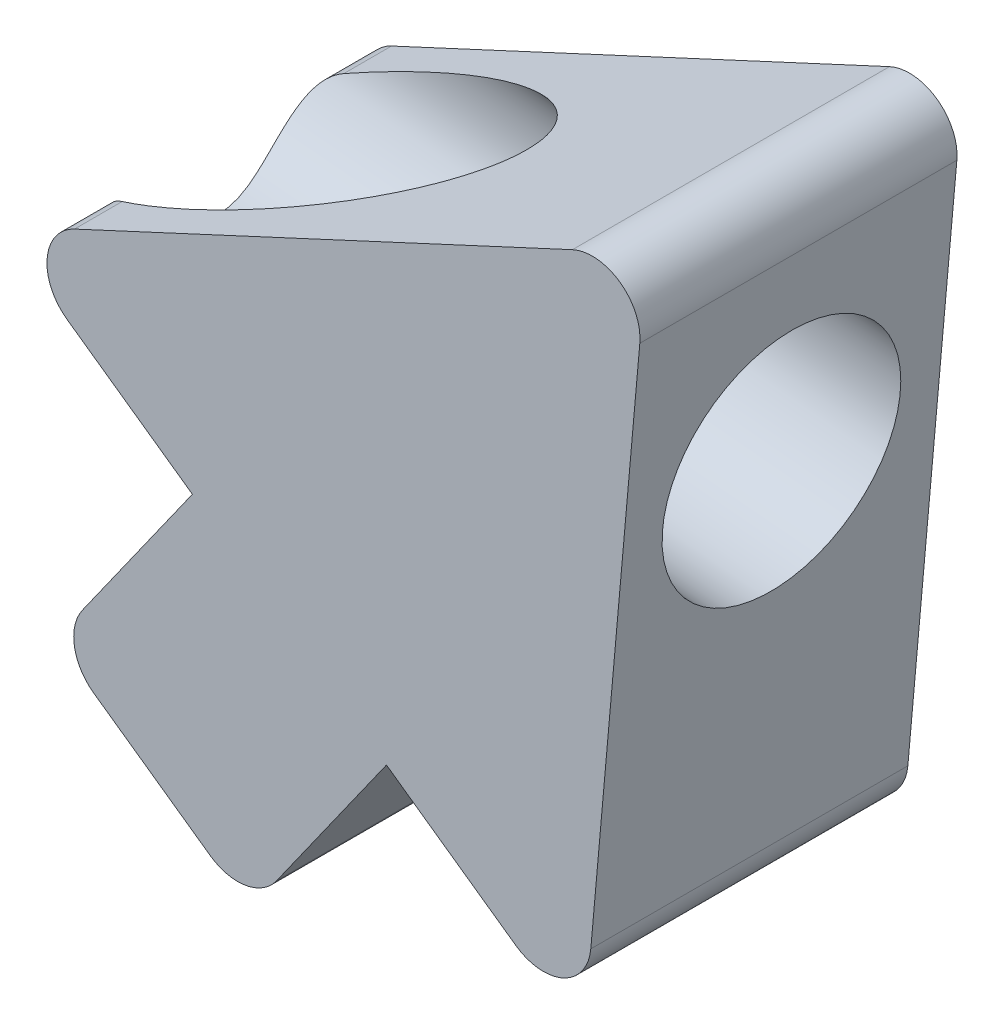
from build123d import *

# Parameters (mm, degrees)
BOSS_EXTRUDE1_DEPTH = 5.08
FILLET1_R           = 0.762
SKETCH2_R           = 1.905
CUT_EXTRUDE1_DEPTH  = 10.53526285


with BuildPart() as part:
    # Sketch1 → Boss-Extrude1 (new body)
    with BuildSketch(Plane.XY):
        Polygon((0, 0), (-10.367708313, -4.812018738), (-7.286004456, -6.993932896), (-9.487605847, -10.103442715), (-6.378096028, -12.305044107), (-4.176494637, -9.195534288), (-1.020567729, -11.43), align=None)
    extrude(amount=BOSS_EXTRUDE1_DEPTH)

    # Fillet1
    fillet1_edges = [part.edges().sort_by_distance(p)[0] for p in [
        (-1.020567729, -11.43, 2.54),
        (-6.378096028, -12.305044107, 2.54),
        (-9.487605847, -10.103442715, 2.54),
        (-10.367708313, -4.812018738, 2.54),
        (0, 0, 2.54),
    ]]
    fillet(fillet1_edges, radius=FILLET1_R)

    # Sketch2 → Cut-Extrude1 (cut, through all)
    with BuildSketch(Plane(origin=(0, 0, 0), x_dir=(0, 0, -1), z_dir=(0.996037458, -0.088934706, 0))):
        with Locations((-2.54, -4.367822715)):
            Circle(SKETCH2_R)
    extrude(amount=-CUT_EXTRUDE1_DEPTH, mode=Mode.SUBTRACT)


solid = part.part
